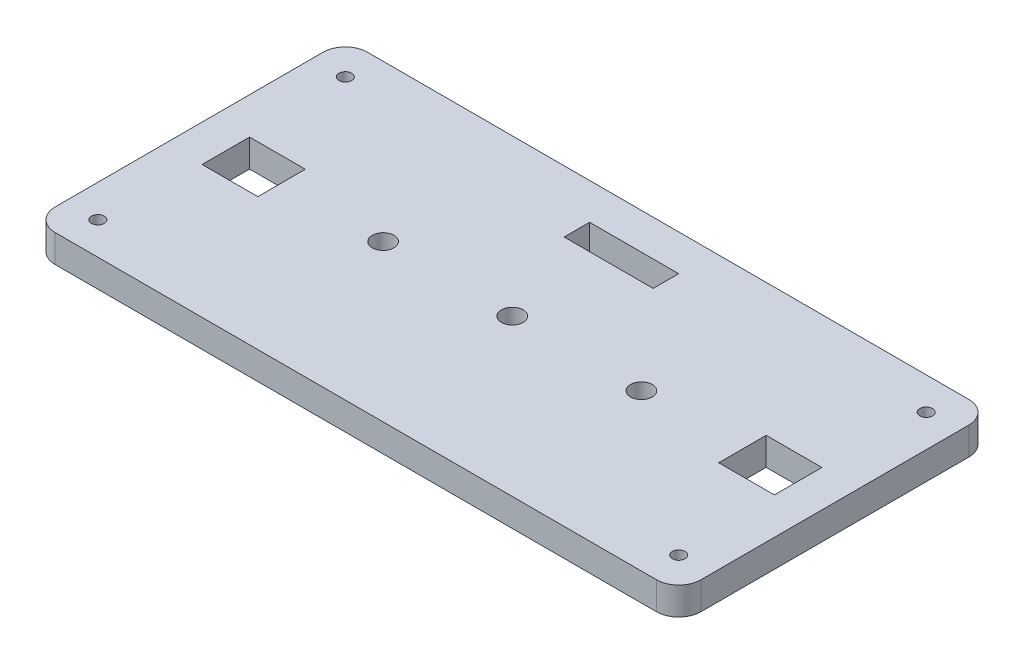
from build123d import *

# Parameters (mm, degrees)
SKETCH1_W           = 147.828
SKETCH1_H           = 71.501
BOSS_EXTRUDE1_DEPTH = 6.35
FILLET1_R           = 5.08
SKETCH2_R           = 2.4892
SKETCH2_W           = 12.7508
SKETCH2_H           = 10.8712
CUT_EXTRUDE1_DEPTH  = 7.35
SKETCH3_R           = 1.4605
CUT_EXTRUDE2_DEPTH  = 7.35
SKETCH5_W           = 20.391623785
SKETCH5_H           = 5.837943421
CUT_EXTRUDE3_DEPTH  = 7.35


with BuildPart() as part:
    # Sketch1 → Boss-Extrude1 (new body)
    with BuildSketch(Plane(origin=(0, 0, 0), x_dir=(1, 0, 0), z_dir=(0, 1, 0))):
        Rectangle(SKETCH1_W, SKETCH1_H)
    extrude(amount=BOSS_EXTRUDE1_DEPTH)

    # Fillet1
    fillet1_edges = [part.edges().sort_by_distance(p)[0] for p in [
        (73.914, 3.175, 35.7505),
        (-73.914, 3.175, 35.7505),
        (-73.914, 3.175, -35.7505),
        (73.914, 3.175, -35.7505),
    ]]
    fillet(fillet1_edges, radius=FILLET1_R)

    # Sketch2 → Cut-Extrude1 (cut, through all)
    with BuildSketch(Plane(origin=(0, 6.35, 0), x_dir=(1, 0, 0), z_dir=(0, 1, 0))):
        with Locations((-29.505731413, 0)):
            Circle(SKETCH2_R)
        with Locations((29.625468587, 0)):
            Circle(SKETCH2_R)
        with Locations((0.059868587, 0)):
            Circle(SKETCH2_R)
        with Locations((59.1312, 0)):
            Rectangle(SKETCH2_W, SKETCH2_H)
        with Locations((-59.1312, 0)):
            Rectangle(SKETCH2_W, SKETCH2_H)
    extrude(amount=-CUT_EXTRUDE1_DEPTH, mode=Mode.SUBTRACT)

    # Sketch3 → Cut-Extrude2 (cut, through all)
    with BuildSketch(Plane(origin=(0, 6.35, 0), x_dir=(1, 0, 0), z_dir=(0, 1, 0))):
        with Locations((-66.4845, 28.321)):
            Circle(SKETCH3_R)
        with Locations((66.4845, 28.321)):
            Circle(SKETCH3_R)
        with Locations((66.4845, -28.321)):
            Circle(SKETCH3_R)
        with Locations((-66.4845, -28.321)):
            Circle(SKETCH3_R)
    extrude(amount=-CUT_EXTRUDE2_DEPTH, mode=Mode.SUBTRACT)

    # Sketch5 → Cut-Extrude3 (cut, through all)
    with BuildSketch(Plane(origin=(0, 6.35, 0), x_dir=(1, 0, 0), z_dir=(0, 1, 0))):
        with Locations((0.498877124, 24.544882744)):
            Rectangle(SKETCH5_W, SKETCH5_H)
    extrude(amount=-CUT_EXTRUDE3_DEPTH, mode=Mode.SUBTRACT)


solid = part.part
